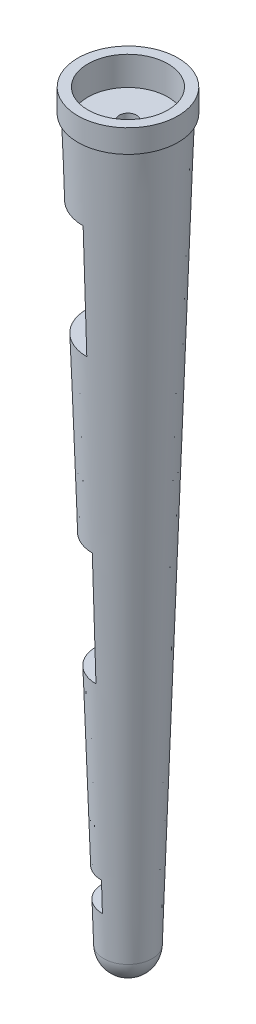
from build123d import *

# Parameters (mm, degrees)
SKETCH2_R               = 11.049
SKETCH2_R_2             = 10.414
BOSS_EXTRUDE1_DEPTH     = 5.08
SKETCH5_W               = 17.78
SKETCH5_H               = 25.4
SKETCH5_H_2             = 6.490496921
CUT_EXTRUDE2_DEPTH      = 154.417080826
SKETCH3_R               = 8.8265
CUT_EXTRUDE3_DEPTH      = 6.35
SKETCH6_R               = 1.905
CUT_EXTRUDE4_DEPTH      = 164.418972888
CUT_EXTRUDE4_DEPTH_BACK = 164.418972888


with BuildPart() as part:
    # Sketch1 → Revolve1 (revolve)
    with BuildSketch(Plane.XY, mode=Mode.PRIVATE) as revolve1_sk:
        with BuildLine():
            Line((0, 11.320953756), (-10.414, 11.320953756))
            Line((-10.414, 11.320953756), (-5.358147253, -147.429046244))
            ThreePointArc((-5.358147253, -147.429046244), (-3.729882948, -151.108963516), (0, -152.619264469))
            Line((0, -152.619264469), (0, 11.320953756))
        make_face()
    revolve(revolve1_sk.sketch.rotate(Axis((0, 11.320953756, 0), (0, -1, 0)), 180), axis=Axis((0, 11.320953756, 0), (0, -1, 0)))

    # Sketch2 → Boss-Extrude1 (add)
    with BuildSketch(Plane(origin=(0, 11.320953756, 0), x_dir=(1, 0, 0), z_dir=(0, 1, 0))):
        with Locations(Location((0, 0, 0), (0, 0, 270))):
            Circle(SKETCH2_R)
        Circle(SKETCH2_R_2, mode=Mode.SUBTRACT)
        Circle(SKETCH2_R_2)
    extrude(amount=BOSS_EXTRUDE1_DEPTH)

    # Sketch5 → Cut-Extrude2 (cut, through all)
    with BuildSketch(Plane(origin=(0, 0, 0), x_dir=(0, 0, -1), z_dir=(1, 0, 0))):
        with Locations((-5.234813406, -17.889046244)):
            Rectangle(SKETCH5_W, SKETCH5_H)
        with Locations((-5.234813406, -81.389046244)):
            Rectangle(SKETCH5_W, SKETCH5_H)
        with Locations((-5.234813406, -135.434294705)):
            Rectangle(SKETCH5_W, SKETCH5_H_2)
    extrude(amount=-CUT_EXTRUDE2_DEPTH, mode=Mode.SUBTRACT)

    # Sketch3 → Cut-Extrude3 (cut)
    with BuildSketch(Plane(origin=(0, 16.400953756, 0), x_dir=(1, 0, 0), z_dir=(0, 1, 0))):
        with Locations(Location((0, 0, 0), (0, 0, 270))):
            Circle(SKETCH3_R)
    extrude(amount=-CUT_EXTRUDE3_DEPTH, mode=Mode.SUBTRACT)

    # Sketch6 → Cut-Extrude4 (cut, two sides)
    with BuildSketch(Plane(origin=(0, 10.050953756, 0), x_dir=(1, 0, 0), z_dir=(0, 1, 0))) as cut_extrude4_sk:
        with Locations(Location((0, 0, 0), (0, 0, 270))):
            Circle(SKETCH6_R)
    extrude(amount=CUT_EXTRUDE4_DEPTH, mode=Mode.SUBTRACT)
    extrude(cut_extrude4_sk.sketch, amount=-CUT_EXTRUDE4_DEPTH_BACK, mode=Mode.SUBTRACT)


solid = part.part
